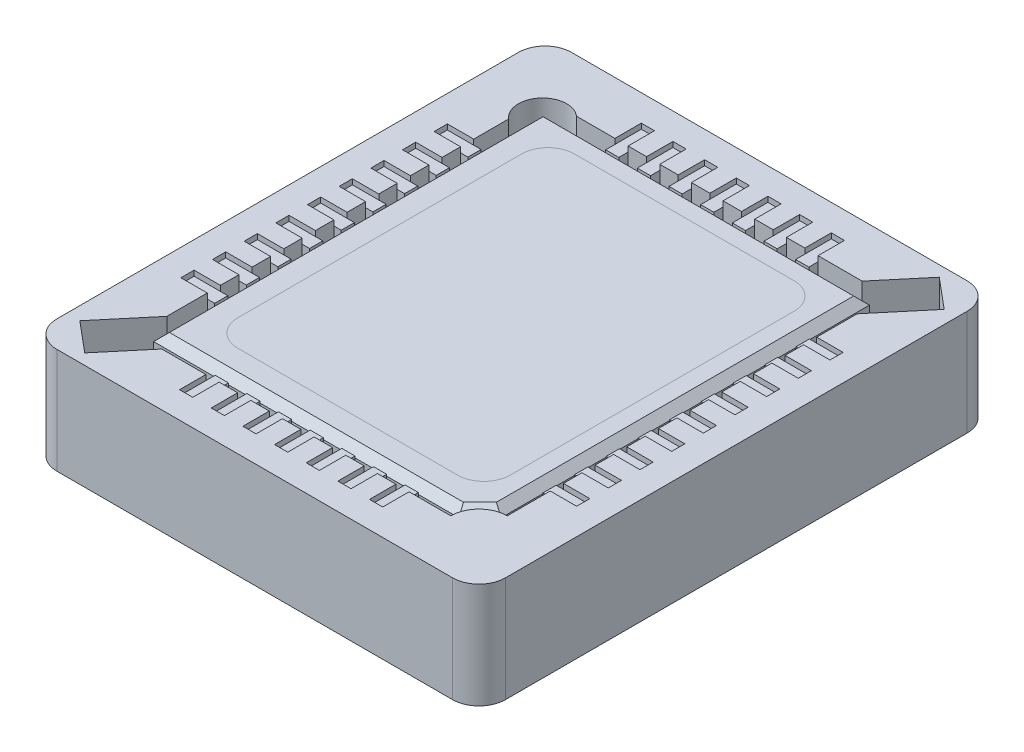
from build123d import *

# Parameters (mm, degrees)
EXTRUIR1_DEPTH        = 4
EXTRUIR2_DEPTH        = 4
CHAFL_N1_SIZE         = 0.3
CROQUIS5_W            = 1
CROQUIS5_H            = 0.5
CROQUIS5_W_2          = 0.5
CROQUIS5_H_2          = 1
CORTAR_EXTRUIR1_DEPTH = 3
CROQUIS6_W            = 0.5
CROQUIS6_H            = 1.350401606
EXTRUIR3_DEPTH        = 2.8
EXTRUIR3_2_DEPTH      = 2.8
EXTRUIR3_3_DEPTH      = 2.8
EXTRUIR3_4_DEPTH      = 2.8
EXTRUIR3_5_DEPTH      = 2.8
EXTRUIR3_6_DEPTH      = 2.8
EXTRUIR3_7_DEPTH      = 2.8
EXTRUIR3_8_DEPTH      = 2.8
EXTRUIR3_9_DEPTH      = 2.8
EXTRUIR3_10_DEPTH     = 2.8
EXTRUIR3_11_DEPTH     = 2.8
EXTRUIR3_12_DEPTH     = 2.8
EXTRUIR3_13_DEPTH     = 2.8
EXTRUIR3_14_DEPTH     = 2.8
CROQUIS6_W_2          = 1.278447122
CROQUIS6_H_2          = 0.5
EXTRUIR3_15_DEPTH     = 2.8
EXTRUIR3_16_DEPTH     = 2.8
EXTRUIR3_17_DEPTH     = 2.8
EXTRUIR3_18_DEPTH     = 2.8
EXTRUIR3_19_DEPTH     = 2.8
EXTRUIR3_20_DEPTH     = 2.8
EXTRUIR3_21_DEPTH     = 2.8
EXTRUIR3_22_DEPTH     = 2.8
EXTRUIR3_23_DEPTH     = 2.8
EXTRUIR3_24_DEPTH     = 2.8
EXTRUIR3_25_DEPTH     = 2.8
EXTRUIR3_26_DEPTH     = 2.8
EXTRUIR3_27_DEPTH     = 2.8
EXTRUIR3_28_DEPTH     = 2.8
EXTRUIR3_29_DEPTH     = 2.8
EXTRUIR3_30_DEPTH     = 2.8
EXTRUIR3_31_DEPTH     = 2.8
EXTRUIR3_32_DEPTH     = 2.8


with BuildPart() as part:
    # Croquis1 → Extruir1 (new body)
    with BuildSketch(Plane(origin=(0, 0, 0), x_dir=(1, 0, 0), z_dir=(0, 1, 0))):
        with BuildLine():
            Line((-7.5, 9.75), (7.5, 9.75))
            ThreePointArc((7.5, 9.75), (8.207106781, 9.457106781), (8.5, 8.75))
            Line((8.5, 8.75), (8.5, -8.75))
            ThreePointArc((8.5, -8.75), (8.207106781, -9.457106781), (7.5, -9.75))
            Line((7.5, -9.75), (-7.5, -9.75))
            ThreePointArc((-7.5, -9.75), (-8.207106781, -9.457106781), (-8.5, -8.75))
            Line((-8.5, -8.75), (-8.5, 8.75))
            ThreePointArc((-8.5, 8.75), (-8.207106781, 9.457106781), (-7.5, 9.75))
        make_face()
        with BuildLine():
            Line((-6.5, -6.582888751), (-8.003801757, -8.375883153))
            Line((-8.003801757, -8.375883153), (-6.854514443, -9.339801546))
            Line((-6.854514443, -9.339801546), (-5.5211325, -7.75))
            Line((-5.5211325, -7.75), (5.429354914, -7.75))
            ThreePointArc((5.429354914, -7.75), (5.7429396, -6.9929396), (6.5, -6.679354914))
            Line((6.5, -6.679354914), (6.5, 6.582888751))
            Line((6.5, 6.582888751), (8.003801757, 8.375883153))
            Line((8.003801757, 8.375883153), (6.854514443, 9.339801546))
            Line((6.854514443, 9.339801546), (5.5211325, 7.75))
            Line((5.5211325, 7.75), (-5.303960394, 7.75))
            ThreePointArc((-5.303960394, 7.75), (-6.5910741, 7.6589259), (-6.5, 6.371812193))
            Line((-6.5, 6.371812193), (-6.5, -6.582888751))
        make_face(mode=Mode.SUBTRACT)
    extrude(amount=EXTRUIR1_DEPTH)

    # Croquis5 → Cortar-Extruir1 (cut)
    with BuildSketch(Plane(origin=(0, 4, 0), x_dir=(1, 0, 0), z_dir=(0, 1, 0))):
        with Locations((7, 0)):
            Rectangle(CROQUIS5_W, CROQUIS5_H)
        with Locations((7, 1.2)):
            Rectangle(CROQUIS5_W, CROQUIS5_H)
        with Locations((7, 2.4)):
            Rectangle(CROQUIS5_W, CROQUIS5_H)
        with Locations((7, 3.6)):
            Rectangle(CROQUIS5_W, CROQUIS5_H)
        with Locations((7, 4.8)):
            Rectangle(CROQUIS5_W, CROQUIS5_H)
        with Locations((7, -4.8)):
            Rectangle(CROQUIS5_W, CROQUIS5_H)
        with Locations((7, -3.6)):
            Rectangle(CROQUIS5_W, CROQUIS5_H)
        with Locations((7, -2.4)):
            Rectangle(CROQUIS5_W, CROQUIS5_H)
        with Locations((7, -1.2)):
            Rectangle(CROQUIS5_W, CROQUIS5_H)
        with Locations((-7, -1.2)):
            Rectangle(CROQUIS5_W, CROQUIS5_H)
        with Locations((-7, -2.4)):
            Rectangle(CROQUIS5_W, CROQUIS5_H)
        with Locations((-7, -3.6)):
            Rectangle(CROQUIS5_W, CROQUIS5_H)
        with Locations((-7, -4.8)):
            Rectangle(CROQUIS5_W, CROQUIS5_H)
        with Locations((-7, 4.8)):
            Rectangle(CROQUIS5_W, CROQUIS5_H)
        with Locations((-7, 3.6)):
            Rectangle(CROQUIS5_W, CROQUIS5_H)
        with Locations((-7, 2.4)):
            Rectangle(CROQUIS5_W, CROQUIS5_H)
        with Locations((-7, 1.2)):
            Rectangle(CROQUIS5_W, CROQUIS5_H)
        with Locations((-7, 0)):
            Rectangle(CROQUIS5_W, CROQUIS5_H)
        with Locations((0, 8.25)):
            Rectangle(CROQUIS5_W_2, CROQUIS5_H_2)
        with Locations((1.2, 8.25)):
            Rectangle(CROQUIS5_W_2, CROQUIS5_H_2)
        with Locations((2.4, 8.25)):
            Rectangle(CROQUIS5_W_2, CROQUIS5_H_2)
        with Locations((3.6, 8.25)):
            Rectangle(CROQUIS5_W_2, CROQUIS5_H_2)
        with Locations((-3.6, 8.25)):
            Rectangle(CROQUIS5_W_2, CROQUIS5_H_2)
        with Locations((-2.4, 8.25)):
            Rectangle(CROQUIS5_W_2, CROQUIS5_H_2)
        with Locations((-1.2, 8.25)):
            Rectangle(CROQUIS5_W_2, CROQUIS5_H_2)
        with Locations((-1.2, -8.25)):
            Rectangle(CROQUIS5_W_2, CROQUIS5_H_2)
        with Locations((-2.4, -8.25)):
            Rectangle(CROQUIS5_W_2, CROQUIS5_H_2)
        with Locations((-3.6, -8.25)):
            Rectangle(CROQUIS5_W_2, CROQUIS5_H_2)
        with Locations((3.6, -8.25)):
            Rectangle(CROQUIS5_W_2, CROQUIS5_H_2)
        with Locations((2.4, -8.25)):
            Rectangle(CROQUIS5_W_2, CROQUIS5_H_2)
        with Locations((1.2, -8.25)):
            Rectangle(CROQUIS5_W_2, CROQUIS5_H_2)
        with Locations((0, -8.25)):
            Rectangle(CROQUIS5_W_2, CROQUIS5_H_2)
    extrude(amount=-CORTAR_EXTRUIR1_DEPTH, mode=Mode.SUBTRACT)


with BuildPart() as body_2:
    # Croquis3 → Extruir2 (new body)
    with BuildSketch(Plane(origin=(0, 4, 0), x_dir=(-1, 0, 0), z_dir=(0, 1, 0))):
        Polygon((-6.147925033, 6.562784471), (-5.347925033, 7.362784471), (6.221552878, 7.362784471), (6.221552878, -7.399598394), (-6.147925033, -7.399598394), align=None)
    extrude(amount=-EXTRUIR2_DEPTH)

    # Chaflán1
    chafl_n1_edges = [body_2.edges().sort_by_distance(p)[0] for p in [
        (5.747925033, 4, 6.962784471),
        (-0.436813922, 4, 7.362784471),
        (-6.221552878, 4, -0.018406961),
        (-0.036813922, 4, -7.399598394),
        (6.147925033, 4, -0.418406961),
    ]]
    chamfer(chafl_n1_edges, length=CHAFL_N1_SIZE)


with BuildPart() as body_3:
    # Croquis6 → Extruir3 (new body)
    with BuildSketch(Plane(origin=(0, 1, 0), x_dir=(1, 0, 0), z_dir=(0, 1, 0))):
        with Locations((-3.6, 8.074799197)):
            Rectangle(CROQUIS6_W, CROQUIS6_H)
    extrude(amount=EXTRUIR3_DEPTH)


with BuildPart() as body_4:
    # Croquis6 → Extruir3 2 (new body)
    with BuildSketch(Plane(origin=(0, 1, 0), x_dir=(1, 0, 0), z_dir=(0, 1, 0))):
        with Locations((-2.4, 8.074799197)):
            Rectangle(CROQUIS6_W, CROQUIS6_H)
    extrude(amount=EXTRUIR3_2_DEPTH)


with BuildPart() as body_5:
    # Croquis6 → Extruir3 3 (new body)
    with BuildSketch(Plane(origin=(0, 1, 0), x_dir=(1, 0, 0), z_dir=(0, 1, 0))):
        with Locations((-1.2, 8.074799197)):
            Rectangle(CROQUIS6_W, CROQUIS6_H)
    extrude(amount=EXTRUIR3_3_DEPTH)


with BuildPart() as body_6:
    # Croquis6 → Extruir3 4 (new body)
    with BuildSketch(Plane(origin=(0, 1, 0), x_dir=(1, 0, 0), z_dir=(0, 1, 0))):
        with Locations((0, 8.074799197)):
            Rectangle(CROQUIS6_W, CROQUIS6_H)
    extrude(amount=EXTRUIR3_4_DEPTH)


with BuildPart() as body_7:
    # Croquis6 → Extruir3 5 (new body)
    with BuildSketch(Plane(origin=(0, 1, 0), x_dir=(1, 0, 0), z_dir=(0, 1, 0))):
        with Locations((1.2, 8.074799197)):
            Rectangle(CROQUIS6_W, CROQUIS6_H)
    extrude(amount=EXTRUIR3_5_DEPTH)


with BuildPart() as body_8:
    # Croquis6 → Extruir3 6 (new body)
    with BuildSketch(Plane(origin=(0, 1, 0), x_dir=(1, 0, 0), z_dir=(0, 1, 0))):
        with Locations((2.4, 8.074799197)):
            Rectangle(CROQUIS6_W, CROQUIS6_H)
    extrude(amount=EXTRUIR3_6_DEPTH)


with BuildPart() as body_9:
    # Croquis6 → Extruir3 7 (new body)
    with BuildSketch(Plane(origin=(0, 1, 0), x_dir=(1, 0, 0), z_dir=(0, 1, 0))):
        with Locations((3.6, 8.074799197)):
            Rectangle(CROQUIS6_W, CROQUIS6_H)
    extrude(amount=EXTRUIR3_7_DEPTH)


with BuildPart() as body_10:
    # Croquis6 → Extruir3 8 (new body)
    with BuildSketch(Plane(origin=(0, 1, 0), x_dir=(1, 0, 0), z_dir=(0, 1, 0))):
        with Locations((3.6, -8.074799197)):
            Rectangle(CROQUIS6_W, CROQUIS6_H)
    extrude(amount=EXTRUIR3_8_DEPTH)


with BuildPart() as body_11:
    # Croquis6 → Extruir3 9 (new body)
    with BuildSketch(Plane(origin=(0, 1, 0), x_dir=(1, 0, 0), z_dir=(0, 1, 0))):
        with Locations((2.4, -8.074799197)):
            Rectangle(CROQUIS6_W, CROQUIS6_H)
    extrude(amount=EXTRUIR3_9_DEPTH)


with BuildPart() as body_12:
    # Croquis6 → Extruir3 10 (new body)
    with BuildSketch(Plane(origin=(0, 1, 0), x_dir=(1, 0, 0), z_dir=(0, 1, 0))):
        with Locations((1.2, -8.074799197)):
            Rectangle(CROQUIS6_W, CROQUIS6_H)
    extrude(amount=EXTRUIR3_10_DEPTH)


with BuildPart() as body_13:
    # Croquis6 → Extruir3 11 (new body)
    with BuildSketch(Plane(origin=(0, 1, 0), x_dir=(1, 0, 0), z_dir=(0, 1, 0))):
        with Locations((0, -8.074799197)):
            Rectangle(CROQUIS6_W, CROQUIS6_H)
    extrude(amount=EXTRUIR3_11_DEPTH)


with BuildPart() as body_14:
    # Croquis6 → Extruir3 12 (new body)
    with BuildSketch(Plane(origin=(0, 1, 0), x_dir=(1, 0, 0), z_dir=(0, 1, 0))):
        with Locations((-1.2, -8.074799197)):
            Rectangle(CROQUIS6_W, CROQUIS6_H)
    extrude(amount=EXTRUIR3_12_DEPTH)


with BuildPart() as body_15:
    # Croquis6 → Extruir3 13 (new body)
    with BuildSketch(Plane(origin=(0, 1, 0), x_dir=(1, 0, 0), z_dir=(0, 1, 0))):
        with Locations((-2.4, -8.074799197)):
            Rectangle(CROQUIS6_W, CROQUIS6_H)
    extrude(amount=EXTRUIR3_13_DEPTH)


with BuildPart() as body_16:
    # Croquis6 → Extruir3 14 (new body)
    with BuildSketch(Plane(origin=(0, 1, 0), x_dir=(1, 0, 0), z_dir=(0, 1, 0))):
        with Locations((-3.6, -8.074799197)):
            Rectangle(CROQUIS6_W, CROQUIS6_H)
    extrude(amount=EXTRUIR3_14_DEPTH)


with BuildPart() as body_17:
    # Croquis6 → Extruir3 15 (new body)
    with BuildSketch(Plane(origin=(0, 1, 0), x_dir=(1, 0, 0), z_dir=(0, 1, 0))):
        with Locations((-6.860776439, 4.8)):
            Rectangle(CROQUIS6_W_2, CROQUIS6_H_2)
    extrude(amount=EXTRUIR3_15_DEPTH)


with BuildPart() as body_18:
    # Croquis6 → Extruir3 16 (new body)
    with BuildSketch(Plane(origin=(0, 1, 0), x_dir=(1, 0, 0), z_dir=(0, 1, 0))):
        with Locations((-6.860776439, 3.6)):
            Rectangle(CROQUIS6_W_2, CROQUIS6_H_2)
    extrude(amount=EXTRUIR3_16_DEPTH)


with BuildPart() as body_19:
    # Croquis6 → Extruir3 17 (new body)
    with BuildSketch(Plane(origin=(0, 1, 0), x_dir=(1, 0, 0), z_dir=(0, 1, 0))):
        with Locations((-6.860776439, 2.4)):
            Rectangle(CROQUIS6_W_2, CROQUIS6_H_2)
    extrude(amount=EXTRUIR3_17_DEPTH)


with BuildPart() as body_20:
    # Croquis6 → Extruir3 18 (new body)
    with BuildSketch(Plane(origin=(0, 1, 0), x_dir=(1, 0, 0), z_dir=(0, 1, 0))):
        with Locations((-6.860776439, 1.2)):
            Rectangle(CROQUIS6_W_2, CROQUIS6_H_2)
    extrude(amount=EXTRUIR3_18_DEPTH)


with BuildPart() as body_21:
    # Croquis6 → Extruir3 19 (new body)
    with BuildSketch(Plane(origin=(0, 1, 0), x_dir=(1, 0, 0), z_dir=(0, 1, 0))):
        with Locations((-6.860776439, 0)):
            Rectangle(CROQUIS6_W_2, CROQUIS6_H_2)
    extrude(amount=EXTRUIR3_19_DEPTH)


with BuildPart() as body_22:
    # Croquis6 → Extruir3 20 (new body)
    with BuildSketch(Plane(origin=(0, 1, 0), x_dir=(1, 0, 0), z_dir=(0, 1, 0))):
        with Locations((-6.860776439, -1.2)):
            Rectangle(CROQUIS6_W_2, CROQUIS6_H_2)
    extrude(amount=EXTRUIR3_20_DEPTH)


with BuildPart() as body_23:
    # Croquis6 → Extruir3 21 (new body)
    with BuildSketch(Plane(origin=(0, 1, 0), x_dir=(1, 0, 0), z_dir=(0, 1, 0))):
        with Locations((-6.860776439, -2.4)):
            Rectangle(CROQUIS6_W_2, CROQUIS6_H_2)
    extrude(amount=EXTRUIR3_21_DEPTH)


with BuildPart() as body_24:
    # Croquis6 → Extruir3 22 (new body)
    with BuildSketch(Plane(origin=(0, 1, 0), x_dir=(1, 0, 0), z_dir=(0, 1, 0))):
        with Locations((-6.860776439, -3.6)):
            Rectangle(CROQUIS6_W_2, CROQUIS6_H_2)
    extrude(amount=EXTRUIR3_22_DEPTH)


with BuildPart() as body_25:
    # Croquis6 → Extruir3 23 (new body)
    with BuildSketch(Plane(origin=(0, 1, 0), x_dir=(1, 0, 0), z_dir=(0, 1, 0))):
        with Locations((-6.860776439, -4.8)):
            Rectangle(CROQUIS6_W_2, CROQUIS6_H_2)
    extrude(amount=EXTRUIR3_23_DEPTH)


with BuildPart() as body_26:
    # Croquis6 → Extruir3 24 (new body)
    with BuildSketch(Plane(origin=(0, 1, 0), x_dir=(1, 0, 0), z_dir=(0, 1, 0))):
        with Locations((6.860776439, -4.8)):
            Rectangle(CROQUIS6_W_2, CROQUIS6_H_2)
    extrude(amount=EXTRUIR3_24_DEPTH)


with BuildPart() as body_27:
    # Croquis6 → Extruir3 25 (new body)
    with BuildSketch(Plane(origin=(0, 1, 0), x_dir=(1, 0, 0), z_dir=(0, 1, 0))):
        with Locations((6.860776439, -3.6)):
            Rectangle(CROQUIS6_W_2, CROQUIS6_H_2)
    extrude(amount=EXTRUIR3_25_DEPTH)


with BuildPart() as body_28:
    # Croquis6 → Extruir3 26 (new body)
    with BuildSketch(Plane(origin=(0, 1, 0), x_dir=(1, 0, 0), z_dir=(0, 1, 0))):
        with Locations((6.860776439, -2.4)):
            Rectangle(CROQUIS6_W_2, CROQUIS6_H_2)
    extrude(amount=EXTRUIR3_26_DEPTH)


with BuildPart() as body_29:
    # Croquis6 → Extruir3 27 (new body)
    with BuildSketch(Plane(origin=(0, 1, 0), x_dir=(1, 0, 0), z_dir=(0, 1, 0))):
        with Locations((6.860776439, -1.2)):
            Rectangle(CROQUIS6_W_2, CROQUIS6_H_2)
    extrude(amount=EXTRUIR3_27_DEPTH)


with BuildPart() as body_30:
    # Croquis6 → Extruir3 28 (new body)
    with BuildSketch(Plane(origin=(0, 1, 0), x_dir=(1, 0, 0), z_dir=(0, 1, 0))):
        with Locations((6.860776439, 0)):
            Rectangle(CROQUIS6_W_2, CROQUIS6_H_2)
    extrude(amount=EXTRUIR3_28_DEPTH)


with BuildPart() as body_31:
    # Croquis6 → Extruir3 29 (new body)
    with BuildSketch(Plane(origin=(0, 1, 0), x_dir=(1, 0, 0), z_dir=(0, 1, 0))):
        with Locations((6.860776439, 1.2)):
            Rectangle(CROQUIS6_W_2, CROQUIS6_H_2)
    extrude(amount=EXTRUIR3_29_DEPTH)


with BuildPart() as body_32:
    # Croquis6 → Extruir3 30 (new body)
    with BuildSketch(Plane(origin=(0, 1, 0), x_dir=(1, 0, 0), z_dir=(0, 1, 0))):
        with Locations((6.860776439, 2.4)):
            Rectangle(CROQUIS6_W_2, CROQUIS6_H_2)
    extrude(amount=EXTRUIR3_30_DEPTH)


with BuildPart() as body_33:
    # Croquis6 → Extruir3 31 (new body)
    with BuildSketch(Plane(origin=(0, 1, 0), x_dir=(1, 0, 0), z_dir=(0, 1, 0))):
        with Locations((6.860776439, 3.6)):
            Rectangle(CROQUIS6_W_2, CROQUIS6_H_2)
    extrude(amount=EXTRUIR3_31_DEPTH)


with BuildPart() as body_34:
    # Croquis6 → Extruir3 32 (new body)
    with BuildSketch(Plane(origin=(0, 1, 0), x_dir=(1, 0, 0), z_dir=(0, 1, 0))):
        with Locations((6.860776439, 4.8)):
            Rectangle(CROQUIS6_W_2, CROQUIS6_H_2)
    extrude(amount=EXTRUIR3_32_DEPTH)


solid = Compound([part.part, body_2.part, body_3.part, body_4.part, body_5.part, body_6.part, body_7.part, body_8.part, body_9.part, body_10.part, body_11.part, body_12.part, body_13.part, body_14.part, body_15.part, body_16.part, body_17.part, body_18.part, body_19.part, body_20.part, body_21.part, body_22.part, body_23.part, body_24.part, body_25.part, body_26.part, body_27.part, body_28.part, body_29.part, body_30.part, body_31.part, body_32.part, body_33.part, body_34.part])
